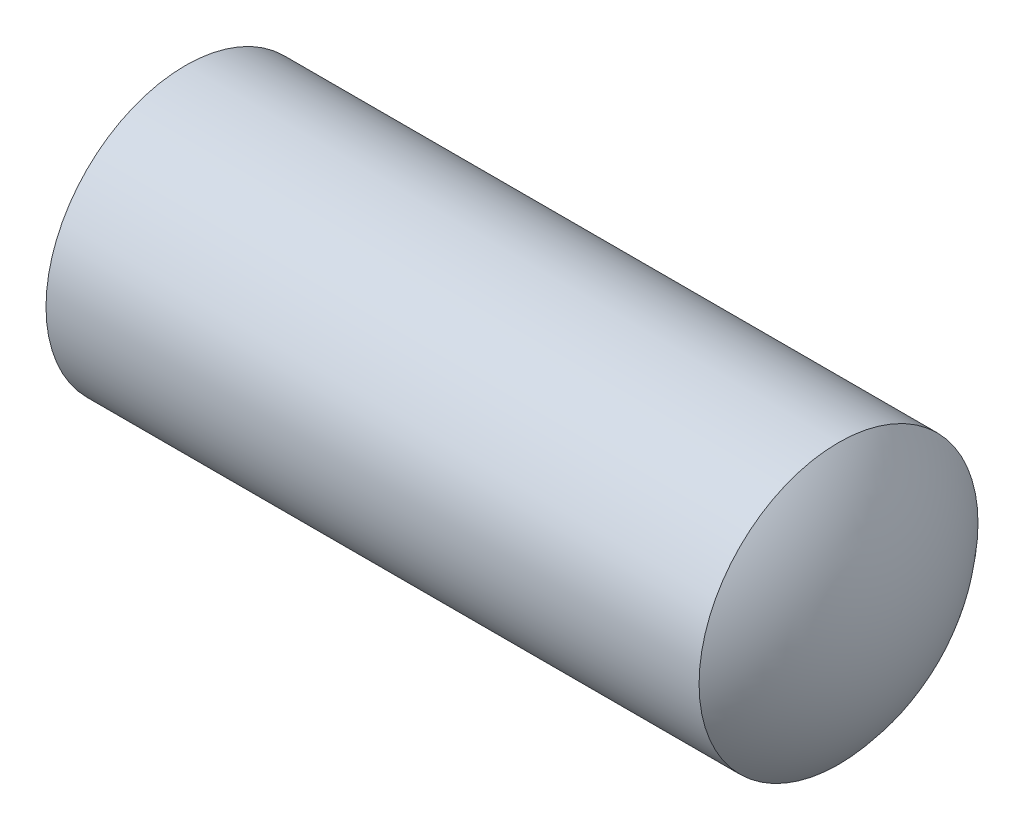
from build123d import *


with BuildPart() as part:
    # BodySke → BaseBody (revolve)
    with BuildSketch(Plane.XY):
        with BuildLine():
            Line((2.552216058, 9.525), (47.157428837, 9.525))
            ThreePointArc((47.157428837, 9.525), (49.8582952, 5.098871191), (50.8, 0))
            Line((50.8, 0), (0, 0))
            ThreePointArc((0, 0), (0.649113009, 4.930502809), (2.552216058, 9.525))
        make_face()
    revolve(axis=Axis((-12.7, 0, 0), (1, 0, 0)))


solid = part.part
